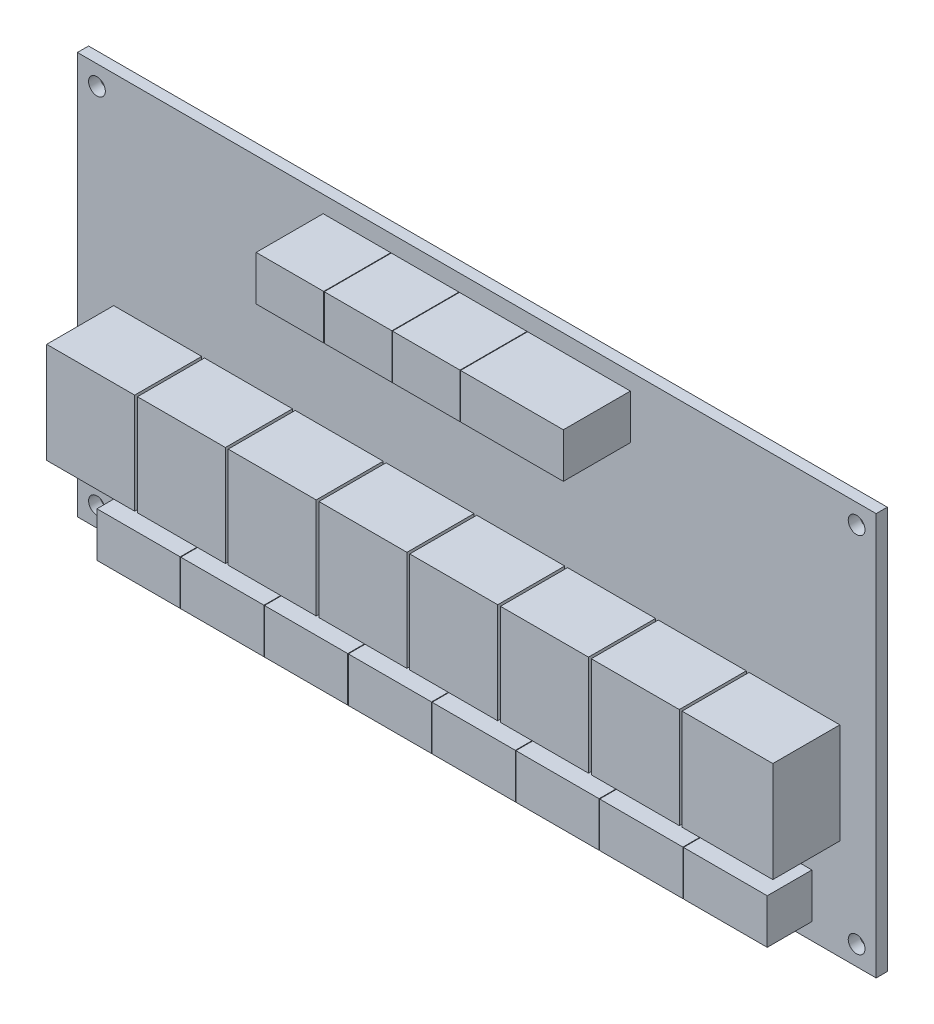
from build123d import *

# Parameters (mm, degrees)
SKETCH_1_W          = 143
SKETCH_1_H          = 72
EXTRUDE_1_DEPTH     = 2
SKETCH_2_R          = 1.5
CUT_EXTRUDE_1_DEPTH = 2
SKETCH_3_W          = 14.9
SKETCH_3_H          = 8
SKETCH_3_W_2        = 15
EXTRUDE_2_DEPTH     = 8
SKETCH_3_3_W        = 15.75
SKETCH_3_3_H        = 18
SKETCH_3_3_W_2      = 16.25
EXTRUDE_3_DEPTH     = 12
SKETCH_3_4_W        = 6.1
SKETCH_3_4_H        = 8
SKETCH_3_4_W_2      = 6
SKETCH_3_4_W_3      = 6.2
EXTRUDE_4_DEPTH     = 12


with BuildPart() as part:
    # 草图1 → 凸台-拉伸1 (new body)
    with BuildSketch(Plane.XY):
        with Locations((71.5, 36)):
            Rectangle(SKETCH_1_W, SKETCH_1_H)
    extrude(amount=EXTRUDE_1_DEPTH)

    # 草图2 → 切除-拉伸1 (cut)
    with BuildSketch(Plane(origin=(0, 0, 0), x_dir=(-1, 0, 0), z_dir=(0, 0, -1))):
        with Locations((-139.5, 68.5)):
            Circle(SKETCH_2_R)
        with Locations((-139.5, 3.5)):
            Circle(SKETCH_2_R)
        with Locations((-3.5, 68.5)):
            Circle(SKETCH_2_R)
        with Locations((-3.5, 3.5)):
            Circle(SKETCH_2_R)
    extrude(amount=-CUT_EXTRUDE_1_DEPTH, mode=Mode.SUBTRACT)

    # 草图3 → 凸台-拉伸2 (add)
    with BuildSketch(Plane.XY.offset(2)):
        with Locations((78.95, 7)):
            Rectangle(SKETCH_3_W, SKETCH_3_H)
        with Locations((63.95, 7)):
            Rectangle(SKETCH_3_W, SKETCH_3_H)
        with Locations((93.95, 7)):
            Rectangle(SKETCH_3_W, SKETCH_3_H)
        with Locations((48.95, 7)):
            Rectangle(SKETCH_3_W, SKETCH_3_H)
        with Locations((108.95, 7)):
            Rectangle(SKETCH_3_W, SKETCH_3_H)
        with Locations((33.95, 7)):
            Rectangle(SKETCH_3_W, SKETCH_3_H)
        with Locations((124, 7)):
            Rectangle(SKETCH_3_W_2, SKETCH_3_H)
        with Locations((18.95, 7)):
            Rectangle(SKETCH_3_W, SKETCH_3_H)
    extrude(amount=EXTRUDE_2_DEPTH)

    # 草图3<3> → 凸台-拉伸3 (add)
    with BuildSketch(Plane.XY.offset(2)):
        with Locations((79.375, 27)):
            Rectangle(SKETCH_3_3_W, SKETCH_3_3_H)
        with Locations((63.125, 27)):
            Rectangle(SKETCH_3_3_W, SKETCH_3_3_H)
        with Locations((95.625, 27)):
            Rectangle(SKETCH_3_3_W, SKETCH_3_3_H)
        with Locations((46.875, 27)):
            Rectangle(SKETCH_3_3_W, SKETCH_3_3_H)
        with Locations((111.875, 27)):
            Rectangle(SKETCH_3_3_W, SKETCH_3_3_H)
        with Locations((30.625, 27)):
            Rectangle(SKETCH_3_3_W, SKETCH_3_3_H)
        with Locations((128.375, 27)):
            Rectangle(SKETCH_3_3_W_2, SKETCH_3_3_H)
        with Locations((14.375, 27)):
            Rectangle(SKETCH_3_3_W, SKETCH_3_3_H)
    extrude(amount=EXTRUDE_3_DEPTH)

    # 草图3<4> → 凸台-拉伸4 (add)
    with BuildSketch(Plane.XY.offset(2)):
        with Locations((47.05, 65)):
            Rectangle(SKETCH_3_4_W, SKETCH_3_4_H)
        with Locations((53.1, 65)):
            Rectangle(SKETCH_3_4_W_2, SKETCH_3_4_H)
        with Locations((59.25, 65)):
            Rectangle(SKETCH_3_4_W, SKETCH_3_4_H)
        with Locations((65.3, 65)):
            Rectangle(SKETCH_3_4_W_2, SKETCH_3_4_H)
        Polygon((68.4, 69), (68.4, 61), (74.5, 61), (74.5, 69), (71.5, 69), align=None)
        with Locations((77.5, 65)):
            Rectangle(SKETCH_3_4_W_2, SKETCH_3_4_H)
        with Locations((83.65, 65)):
            Rectangle(SKETCH_3_4_W, SKETCH_3_4_H)
        with Locations((89.75, 65)):
            Rectangle(SKETCH_3_4_W, SKETCH_3_4_H)
        with Locations((95.9, 65)):
            Rectangle(SKETCH_3_4_W_3, SKETCH_3_4_H)
    extrude(amount=EXTRUDE_4_DEPTH)


solid = part.part
